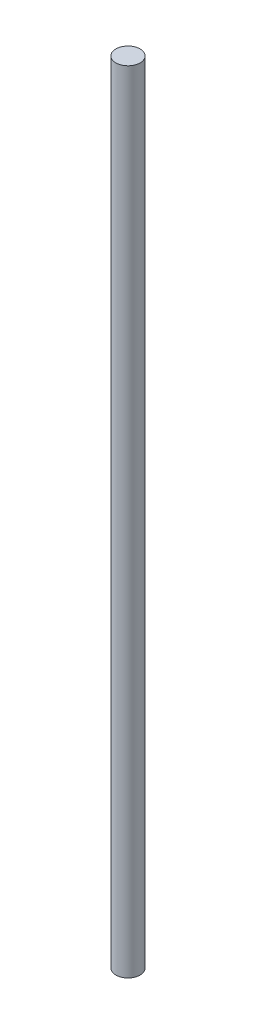
from build123d import *

# Parameters (mm, degrees)
SKETCH1_R           = 5.842
BOSS_EXTRUDE1_DEPTH = 381


with BuildPart() as part:
    # Sketch1 → Boss-Extrude1 (new body)
    with BuildSketch(Plane(origin=(0, 0, 0), x_dir=(1, 0, 0), z_dir=(0, 1, 0))):
        Circle(SKETCH1_R)
    extrude(amount=BOSS_EXTRUDE1_DEPTH)


solid = part.part
